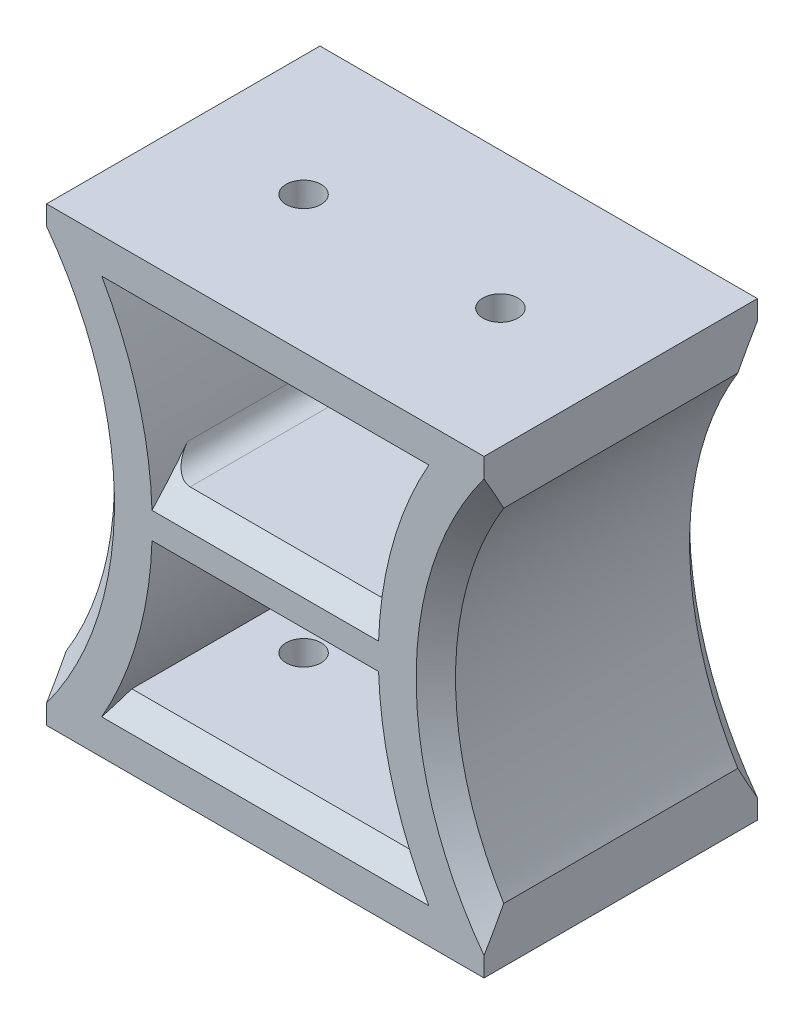
from build123d import *

# Parameters (mm, degrees)
BOSS_EXTRU_1_DEPTH      = 12.5
BOSS_EXTRU_1_DEPTH_BACK = 12.5
ESQUISSE1_W             = 40
ESQUISSE1_H             = 41.3
ENL_V_MAT_EXTRU_1_REACH = 40.098
ENL_V_MAT_EXTRU_2_REACH = 49.56
ESQUISSE3_R             = 1.6
ENL_V_MAT_EXTRU_3_REACH = 49.56
ESQUISSE4_R             = 1.6
CHANFREIN7_SIZE         = 1.8
CONG_4_R                = 2


with BuildPart() as part:
    # Esquisse1 → Boss.-Extru.1 (new, two sides: drawn at the far end of the back side and taken through both)
    with BuildSketch(Plane.XY.offset(-BOSS_EXTRU_1_DEPTH_BACK)):
        Rectangle(ESQUISSE1_W, ESQUISSE1_H)
    extrude(amount=BOSS_EXTRU_1_DEPTH + BOSS_EXTRU_1_DEPTH_BACK)

    # Esquisse2 → Enlèv. mat.-Extru.1 (cut, up to next)
    with BuildSketch(Plane.XY.offset(12.5), mode=Mode.PRIVATE) as enl_v_mat_extru_1_sk1:
        with BuildLine():
            Line((-20, 15.65), (-20, -15.65))
            ThreePointArc((-20, -15.65), (-15.594481827, 0), (-20, 15.65))
        make_face()
    enl_v_mat_extru_1_tool1 = extrude(enl_v_mat_extru_1_sk1.sketch, amount=-ENL_V_MAT_EXTRU_1_REACH, mode=Mode.PRIVATE) & part.part
    # Esquisse2 → Enlèv. mat.-Extru.1 (cut, up to next)
    with BuildSketch(Plane.XY.offset(12.5), mode=Mode.PRIVATE) as enl_v_mat_extru_1_sk2:
        with BuildLine():
            Line((20, 15.65), (20, -15.65))
            ThreePointArc((20, -15.65), (15.594481827, 0), (20, 15.65))
        make_face()
    enl_v_mat_extru_1_tool2 = extrude(enl_v_mat_extru_1_sk2.sketch, amount=-ENL_V_MAT_EXTRU_1_REACH, mode=Mode.PRIVATE) & part.part
    # Esquisse2 → Enlèv. mat.-Extru.1 (cut, up to next)
    with BuildSketch(Plane.XY.offset(12.5), mode=Mode.PRIVATE) as enl_v_mat_extru_1_sk3:
        with BuildLine():
            Line((-14, -15.65), (14, -15.65))
            ThreePointArc((14, -15.65), (11.637851253, -9.491102252), (10.46424155, -3))
            Line((10.46424155, -3), (-10.46424155, -3))
            ThreePointArc((-10.46424155, -3), (-11.637851253, -9.491102252), (-14, -15.65))
        make_face()
    enl_v_mat_extru_1_tool3 = extrude(enl_v_mat_extru_1_sk3.sketch, amount=-ENL_V_MAT_EXTRU_1_REACH, mode=Mode.PRIVATE) & part.part
    # Esquisse2 → Enlèv. mat.-Extru.1 (cut, up to next)
    with BuildSketch(Plane.XY.offset(12.5), mode=Mode.PRIVATE) as enl_v_mat_extru_1_sk4:
        with BuildLine():
            Line((-14, 15.65), (14, 15.65))
            ThreePointArc((14, 15.65), (11.637851253, 9.491102252), (10.46424155, 3))
            Line((10.46424155, 3), (-10.46424155, 3))
            ThreePointArc((-10.46424155, 3), (-11.637851253, 9.491102252), (-14, 15.65))
        make_face()
    enl_v_mat_extru_1_tool4 = extrude(enl_v_mat_extru_1_sk4.sketch, amount=-ENL_V_MAT_EXTRU_1_REACH, mode=Mode.PRIVATE) & part.part
    add(enl_v_mat_extru_1_tool1.solids().sort_by_distance((-18.226209, 0, 12.5))[0], mode=Mode.SUBTRACT)
    add(enl_v_mat_extru_1_tool2.solids().sort_by_distance((18.226209, 0, 12.5))[0], mode=Mode.SUBTRACT)
    add(enl_v_mat_extru_1_tool3.solids().sort_by_distance((0, -9.638348, 12.5))[0], mode=Mode.SUBTRACT)
    add(enl_v_mat_extru_1_tool4.solids().sort_by_distance((0, 9.638348, 12.5))[0], mode=Mode.SUBTRACT)

    # Esquisse3 → Enlèv. mat.-Extru.2 (cut, up to next)
    with BuildSketch(Plane(origin=(0, 20.65, 0), x_dir=(1, 0, 0), z_dir=(0, 1, 0)), mode=Mode.PRIVATE) as enl_v_mat_extru_2_sk1:
        with Locations((-9, 0)):
            Circle(ESQUISSE3_R)
    enl_v_mat_extru_2_tool1 = extrude(enl_v_mat_extru_2_sk1.sketch, amount=-ENL_V_MAT_EXTRU_2_REACH, mode=Mode.PRIVATE) & part.part
    # Esquisse3 → Enlèv. mat.-Extru.2 (cut, up to next)
    with BuildSketch(Plane(origin=(0, 20.65, 0), x_dir=(1, 0, 0), z_dir=(0, 1, 0)), mode=Mode.PRIVATE) as enl_v_mat_extru_2_sk2:
        with Locations((9, 0)):
            Circle(ESQUISSE3_R)
    enl_v_mat_extru_2_tool2 = extrude(enl_v_mat_extru_2_sk2.sketch, amount=-ENL_V_MAT_EXTRU_2_REACH, mode=Mode.PRIVATE) & part.part
    add(enl_v_mat_extru_2_tool1.solids().sort_by_distance((-9, 20.65, 0))[0], mode=Mode.SUBTRACT)
    add(enl_v_mat_extru_2_tool2.solids().sort_by_distance((9, 20.65, 0))[0], mode=Mode.SUBTRACT)

    # Esquisse4 → Enlèv. mat.-Extru.3 (cut, up to next)
    with BuildSketch(Plane.XZ.offset(20.65), mode=Mode.PRIVATE) as enl_v_mat_extru_3_sk1:
        with Locations((-9, 0)):
            Circle(ESQUISSE4_R)
    enl_v_mat_extru_3_tool1 = extrude(enl_v_mat_extru_3_sk1.sketch, amount=-ENL_V_MAT_EXTRU_3_REACH, mode=Mode.PRIVATE) & part.part
    # Esquisse4 → Enlèv. mat.-Extru.3 (cut, up to next)
    with BuildSketch(Plane.XZ.offset(20.65), mode=Mode.PRIVATE) as enl_v_mat_extru_3_sk2:
        with Locations((9, 0)):
            Circle(ESQUISSE4_R)
    enl_v_mat_extru_3_tool2 = extrude(enl_v_mat_extru_3_sk2.sketch, amount=-ENL_V_MAT_EXTRU_3_REACH, mode=Mode.PRIVATE) & part.part
    add(enl_v_mat_extru_3_tool1.solids().sort_by_distance((-9, -20.65, 0))[0], mode=Mode.SUBTRACT)
    add(enl_v_mat_extru_3_tool2.solids().sort_by_distance((9, -20.65, 0))[0], mode=Mode.SUBTRACT)

    # Chanfrein7
    chanfrein7_edges = [part.edges().sort_by_distance(p)[0] for p in [
        (-15.594481827, 0, -12.5),
        (15.594481827, 0, -12.5),
        (15.594481827, 0, 12.5),
        (-15.594481827, 0, 12.5),
        (0, -3, -12.5),
        (0, 3, -12.5),
        (0, -3, 12.5),
        (0, 3, 12.5),
        (0, 15.65, 12.5),
        (0, -15.65, 12.5),
        (0, -15.65, -12.5),
        (0, 15.65, -12.5),
    ]]
    chamfer(chanfrein7_edges, length=CHANFREIN7_SIZE)

    # Congé4
    cong_4_edges = [part.edges().sort_by_distance(p)[0] for p in [
        (10.46424155, 3, 0),
        (-10.46424155, 3, 0),
        (10.46424155, -3, 0),
        (-10.46424155, -3, 0),
    ]]
    fillet(cong_4_edges, radius=CONG_4_R)


solid = part.part
